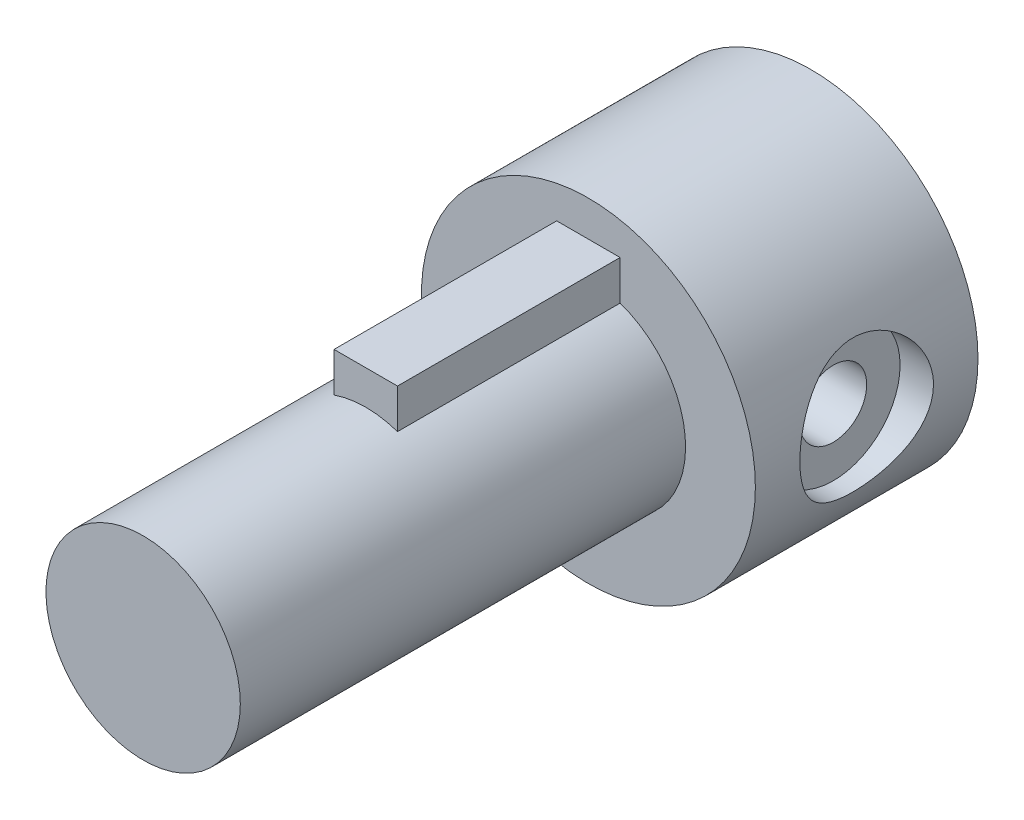
from build123d import *

# Parameters (mm, degrees)
SKETCH2_R               = 7.5
SKETCH2_R_2             = 3
BOSS_EXTRUDE1_DEPTH     = 10
CUT_EXTRUDE1_DEPTH      = 15.577379737
CUT_EXTRUDE1_DEPTH_BACK = 15.577379737
SKETCH3_R               = 3
SKETCH3_5_R             = 4.121610416
SKETCH3_5_R_2           = 1.5
BOSS_EXTRUDE6_DEPTH     = 6
BOSS_EXTRUDE7_DEPTH     = 10
SKETCH5_R               = 3
CUT_EXTRUDE3_DEPTH      = 10
SKETCH6_R               = 4.365
BOSS_EXTRUDE8_DEPTH     = 10


with BuildPart() as part:
    # Sketch2 → Boss-Extrude1 (new body)
    with BuildSketch(Plane.XY):
        Circle(SKETCH2_R)
        Circle(SKETCH2_R_2, mode=Mode.SUBTRACT)
    extrude(amount=BOSS_EXTRUDE1_DEPTH)

    # Sketch3 → Cut-Extrude1 (cut, two sides: drawn at the far end of the back side and taken through both)
    with BuildSketch(Plane(origin=(0, 0, 0), x_dir=(0, -1, 0), z_dir=(1, 0, 0)).offset(-CUT_EXTRUDE1_DEPTH_BACK)):
        with Locations((0, -5)):
            Circle(SKETCH3_R)
    extrude(amount=CUT_EXTRUDE1_DEPTH + CUT_EXTRUDE1_DEPTH_BACK, mode=Mode.SUBTRACT)

    # Sketch3_5 → Boss-Extrude6 (add, symmetric)
    with BuildSketch(Plane(origin=(0, 0, 0), x_dir=(0, -1, 0), z_dir=(1, 0, 0))):
        with Locations((0, -5)):
            Circle(SKETCH3_5_R)
        with Locations((0, -5)):
            Circle(SKETCH3_5_R_2, mode=Mode.SUBTRACT)
    extrude(amount=BOSS_EXTRUDE6_DEPTH, both=True)

    # Sketch4 → Boss-Extrude7 (add)
    with BuildSketch(Plane.XY.offset(10)):
        with BuildLine():
            ThreePointArc((-1.425, 4.125845368), (0, -4.365), (1.425, 4.125845368))
            Line((1.425, 4.125845368), (1.425, 5.9))
            Line((1.425, 5.9), (-1.425, 5.9))
            Line((-1.425, 5.9), (-1.425, 4.125845368))
        make_face()
    extrude(amount=BOSS_EXTRUDE7_DEPTH)

    # Sketch5 → Cut-Extrude3 (cut)
    with BuildSketch(Plane(origin=(0, 0, 0), x_dir=(-1, 0, 0), z_dir=(0, 0, -1))):
        Circle(SKETCH5_R)
    extrude(amount=-CUT_EXTRUDE3_DEPTH, mode=Mode.SUBTRACT)

    # Sketch6 → Boss-Extrude8 (add)
    with BuildSketch(Plane.XY.offset(20)):
        Circle(SKETCH6_R)
    extrude(amount=BOSS_EXTRUDE8_DEPTH)


solid = part.part
